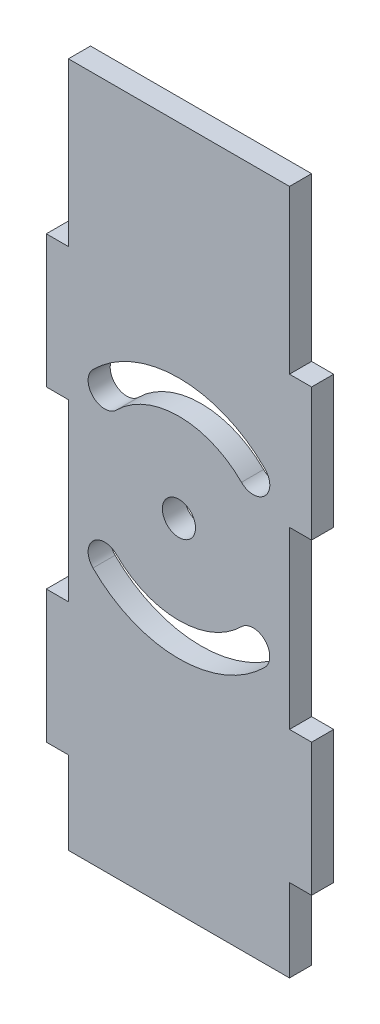
from build123d import *

# Parameters (mm, degrees)
BOSS_EXTRUDE1_DEPTH = 3.175
SKETCH3_R           = 2.38125
CUT_EXTRUDE2_DEPTH  = 3.175


with BuildPart() as part:
    # Sketch1 → Boss-Extrude1 (new body)
    with BuildSketch(Plane.XY):
        Polygon((-3.175, 365.778475051), (-34.925, 365.778475051), (-34.925, 342.421386502), (-38.1, 342.421386502), (-38.1, 323.371386502), (-34.925, 323.371386502), (-34.925, 298.240631325), (-38.1, 298.240631325), (-38.1, 279.190631325), (-34.925, 279.190631325), (-34.925, 267.318840011), (-3.175, 267.318840011), (-3.175, 279.190631325), (0, 279.190631325), (0, 298.240631325), (-3.175, 298.240631325), (-3.175, 323.371386502), (0, 323.371386502), (0, 342.421386502), (-3.175, 342.421386502), align=None)
    extrude(amount=BOSS_EXTRUDE1_DEPTH)

    # Sketch3 → Cut-Extrude2 (cut)
    with BuildSketch(Plane.XY.offset(3.175)):
        with Locations((-19.05, 316.548657531)):
            Circle(SKETCH3_R)
        with BuildLine():
            ThreePointArc((-6.700444288, 328.898213243), (-19.05, 334.013566708), (-31.399555712, 328.898213243))
            ThreePointArc((-31.399555712, 328.898213243), (-31.399555712, 325.530617198), (-28.031959666, 325.530617198))
            ThreePointArc((-28.031959666, 325.530617198), (-19.05, 329.251066708), (-10.068040334, 325.530617198))
            ThreePointArc((-10.068040334, 325.530617198), (-6.700444288, 325.530617198), (-6.700444288, 328.898213243))
        make_face()
        with BuildLine():
            ThreePointArc((-31.397852166, 304.200805365), (-19.05, 299.086157531), (-6.702147834, 304.200805365))
            ThreePointArc((-6.702147834, 304.200805365), (-6.702147834, 307.56840141), (-10.069743879, 307.56840141))
            ThreePointArc((-10.069743879, 307.56840141), (-19.05, 303.848657531), (-28.030256121, 307.56840141))
            ThreePointArc((-28.030256121, 307.56840141), (-31.397852166, 307.56840141), (-31.397852166, 304.200805365))
        make_face()
    extrude(amount=-CUT_EXTRUDE2_DEPTH, mode=Mode.SUBTRACT)


solid = part.part
